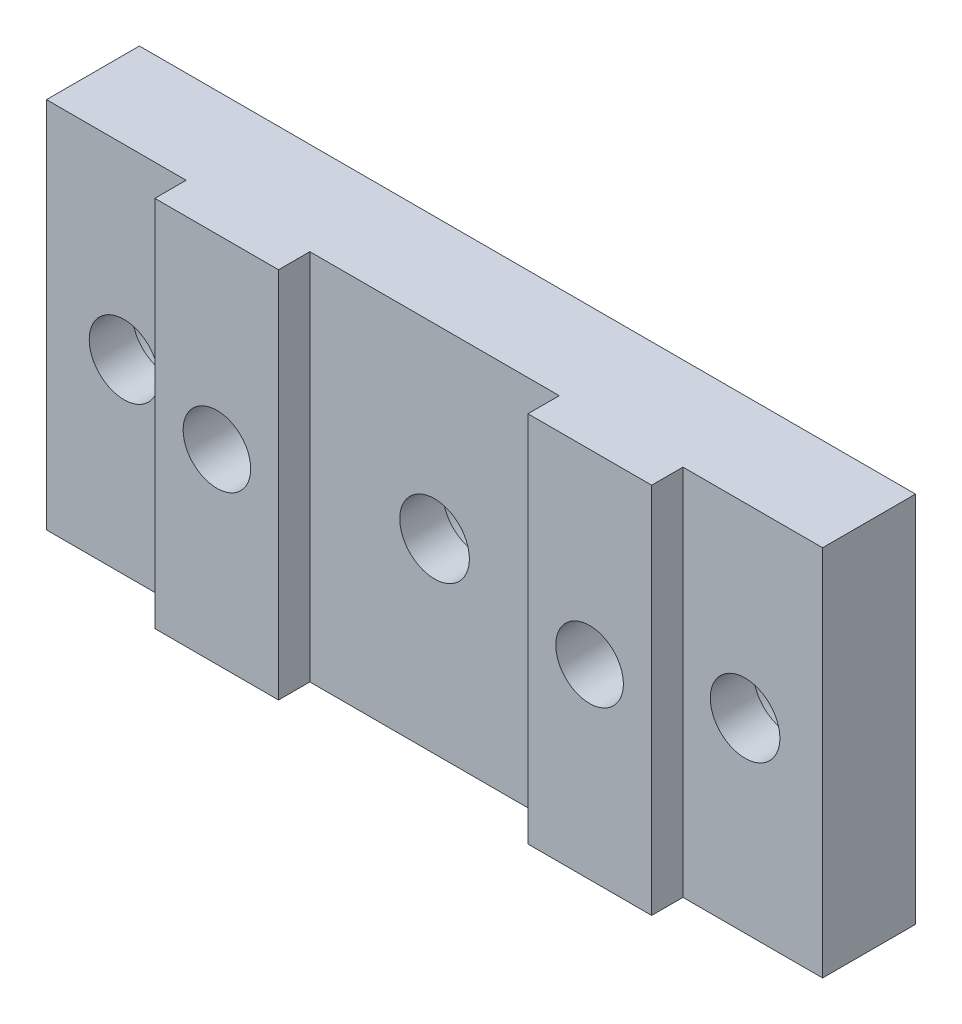
from build123d import *

# Parameters (mm, degrees)
SKETCH1_W             = 39.6748
SKETCH1_H             = 19.05
EXTRUDE1_DEPTH        = 6.35
SKETCH2_W             = 7.1374
SKETCH2_H             = 1.6002
SKETCH2_W_2           = 12.7508
CUT_EXTRUDE1_DEPTH    = 20.05
HOLE1_D               = 3.556
HOLE1_CBORE_D         = 6.35
HOLE1_CBORE_DEPTH     = 2.54
F_8_32_TAPPED_HOLE1_D = 3.4544


with BuildPart() as part:
    # Sketch1 → Extrude1 (new body)
    with BuildSketch(Plane.XY):
        with Locations((19.8374, 9.525)):
            Rectangle(SKETCH1_W, SKETCH1_H)
    extrude(amount=EXTRUDE1_DEPTH)

    # Sketch2 → Cut-Extrude1 (cut, through all)
    with BuildSketch(Plane.XZ):
        with Locations((3.5687, 5.5499)):
            Rectangle(SKETCH2_W, SKETCH2_H)
        with Locations((19.8374, 5.5499)):
            Rectangle(SKETCH2_W_2, SKETCH2_H)
        with Locations((36.1061, 5.5499)):
            Rectangle(SKETCH2_W, SKETCH2_H)
    extrude(amount=-CUT_EXTRUDE1_DEPTH, mode=Mode.SUBTRACT)

    # Hole1 (through all)
    with Locations(Plane(origin=(0, 0, 0), x_dir=(-1, 0, 0), z_dir=(0, 0, -1))):
        with Locations((-3.9624, 9.525), (-19.8374, 9.525), (-35.7124, 9.525)):
            CounterBoreHole(HOLE1_D / 2, HOLE1_CBORE_D / 2, HOLE1_CBORE_DEPTH)

    # #8-32 Tapped Hole1 (through all)
    with Locations(Plane(origin=(0, 0, 0), x_dir=(-1, 0, 0), z_dir=(0, 0, -1))):
        with Locations((-10.3124, 9.525), (-29.3624, 9.525)):
            Hole(F_8_32_TAPPED_HOLE1_D / 2)


solid = part.part
